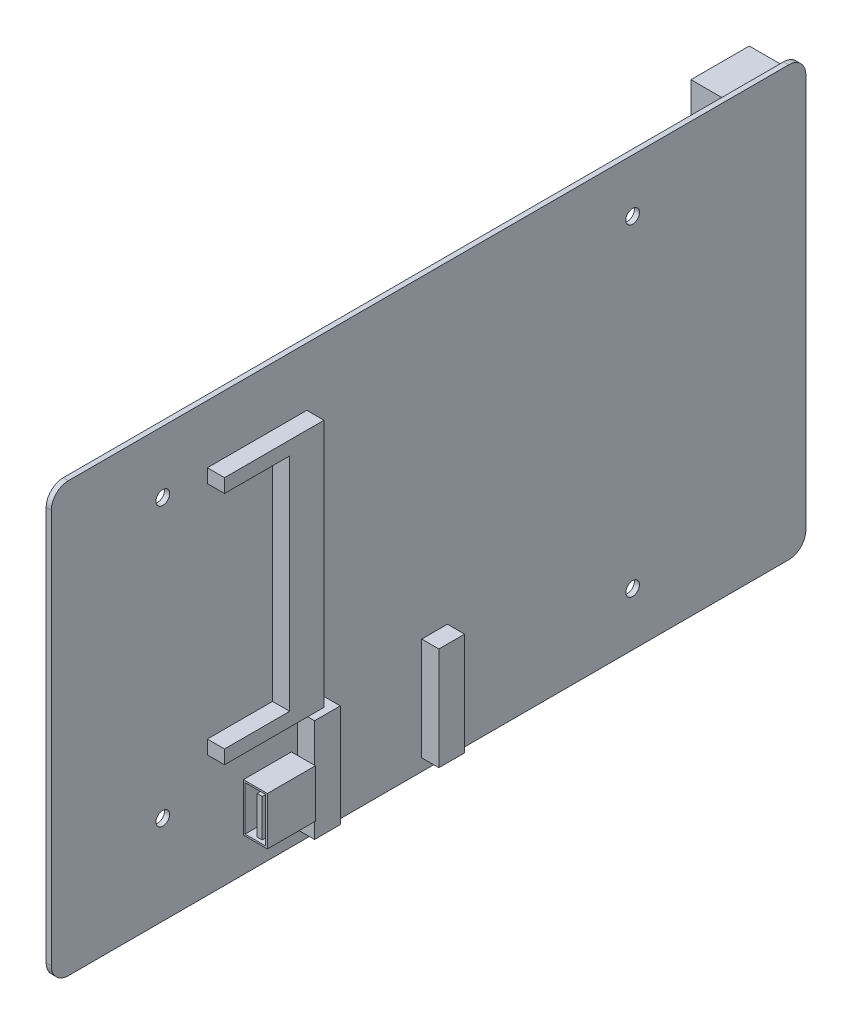
from build123d import *

# Parameters (mm, degrees)
SKETCH_1_W             = 220
SKETCH_1_H             = 125
EXTRUDE_1_DEPTH        = 1.5
FILLET_1_R             = 5
SKETCH_2_W             = 7.5
SKETCH_2_H             = 30
EXTRUDE_2_DEPTH        = 5
SKETCH_3_W             = 14
SKETCH_3_H             = 14
EXTRUDE_3_DEPTH        = 7
SKETCH_4_W             = 6
SKETCH_4_H             = 13
SKETCH_4_W_2           = 1.5
SKETCH_4_H_2           = 11
CUT_EXTRUDE_1_DEPTH    = 10
SKETCH_5_R             = 2
CUT_EXTRUDE_2_DEPTH    = 2.5
SKETCH_6_W             = 82.5
SKETCH_6_H             = 63.5
EXTRUDE_4_DEPTH        = 18
FILLET_2_R             = 1
SKETCH_7_W             = 82.5
SKETCH_7_H             = 2.5
CUT_EXTRUDE_3_DEPTH    = 10
PATTERN_LINEAR_1_COUNT = 18
PATTERN_LINEAR_1_PITCH = 3.4
SKETCH_8_W             = 1.5
SKETCH_8_H             = 63.5
CUT_EXTRUDE_4_DEPTH    = 10
PATTERN_LINEAR_2_COUNT = 5
PATTERN_LINEAR_2_PITCH = 11
SKETCH_9_W             = 8.75
SKETCH_9_H             = 39
EXTRUDE_5_DEPTH        = 11
SKETCH_10_W            = 2
SKETCH_10_H            = 11.5
SKETCH_10_H_2          = 22
CUT_EXTRUDE_5_DEPTH    = 7.5
SKETCH_11_W            = 17
SKETCH_11_H            = 14
EXTRUDE_6_DEPTH        = 15
SKETCH_12_W            = 5.5
SKETCH_12_H            = 13
SKETCH_12_W_2          = 1.5
SKETCH_12_H_2          = 11
CUT_EXTRUDE_6_DEPTH    = 10
SKETCH_13_W            = 16
SKETCH_13_H            = 16.5
EXTRUDE_7_DEPTH        = 13.5
CUT_EXTRUDE_7_DEPTH    = 13.5
PATTERN_LINEAR_3_COUNT = 2
PATTERN_LINEAR_3_PITCH = 20.5


with BuildPart() as part:
    # 草图1 → 凸台-拉伸1 (new body)
    with BuildSketch(Plane(origin=(0, 0, 0), x_dir=(0, 0, -1), z_dir=(1, 0, 0))):
        Rectangle(SKETCH_1_W, SKETCH_1_H)
    extrude(amount=-EXTRUDE_1_DEPTH)

    # 圆角1
    fillet_1_edges = [part.edges().sort_by_distance(p)[0] for p in [
        (-0.75, 62.5, 110),
        (-0.75, 62.5, -110),
        (-0.75, -62.5, -110),
        (-0.75, -62.5, 110),
    ]]
    fillet(fillet_1_edges, radius=FILLET_1_R)

    # 草图2 → 凸台-拉伸2 (add)
    with BuildSketch(Plane(origin=(0, 0, 0), x_dir=(0, 0, -1), z_dir=(1, 0, 0))):
        Polygon((-35.5, 45.5), (-64.5, 45.5), (-64.5, 41.5), (-45.5, 41.5), (-45.5, -23), (-64.5, -23), (-64.5, -27), (-35.5, -27), align=None)
        with Locations((-34.5, -44)):
            Rectangle(SKETCH_2_W, SKETCH_2_H)
        with Locations((1.75, -44)):
            Rectangle(SKETCH_2_W, SKETCH_2_H)
    extrude(amount=EXTRUDE_2_DEPTH)

    # 草图3 → 凸台-拉伸3 (add)
    with BuildSketch(Plane(origin=(0, 0, 0), x_dir=(0, 0, -1), z_dir=(1, 0, 0))):
        with Locations((-47, -45.5)):
            Rectangle(SKETCH_3_W, SKETCH_3_H)
    extrude(amount=EXTRUDE_3_DEPTH)

    # 草图4 → 切除-拉伸1 (cut)
    with BuildSketch(Plane.XY.offset(54)):
        with Locations((3.5, -45.5)):
            Rectangle(SKETCH_4_W, SKETCH_4_H)
        with Locations((4.75, -45.5)):
            Rectangle(SKETCH_4_W_2, SKETCH_4_H_2, mode=Mode.SUBTRACT)
    extrude(amount=-CUT_EXTRUDE_1_DEPTH, mode=Mode.SUBTRACT)

    # 草图5 → 切除-拉伸2 (cut, through all)
    with BuildSketch(Plane(origin=(0, 0, 0), x_dir=(0, 0, -1), z_dir=(1, 0, 0))):
        with Locations((-77.5, 44.5)):
            Circle(SKETCH_5_R)
        with Locations((-77.5, -36.5)):
            Circle(SKETCH_5_R)
        with Locations((59.5, 47)):
            Circle(SKETCH_5_R)
        with Locations((59.5, -47)):
            Circle(SKETCH_5_R)
    extrude(amount=-CUT_EXTRUDE_2_DEPTH, mode=Mode.SUBTRACT)

    # 草图6 → 凸台-拉伸4 (add)
    with BuildSketch(Plane.ZY.offset(1.5)):
        with Locations((-6.25, 10.75)):
            Rectangle(SKETCH_6_W, SKETCH_6_H)
    extrude(amount=EXTRUDE_4_DEPTH)

    # 圆角2
    fillet_2_edges = [part.edges().sort_by_distance(p)[0] for p in [
        (-19.5, 10.75, -47.5),
        (-19.5, 10.75, 35),
    ]]
    fillet(fillet_2_edges, radius=FILLET_2_R)

    # 草图7 → 切除-拉伸3 (cut)
    with BuildSketch(Plane.ZY.offset(19.5)):
        with Locations((-6.25, -18.75)):
            Rectangle(SKETCH_7_W, SKETCH_7_H)
    cut_extrude_3 = extrude(amount=-CUT_EXTRUDE_3_DEPTH, mode=Mode.SUBTRACT)

    # 阵列(线性)1: 切除-拉伸3 ×18
    with Locations(*[(0, i * PATTERN_LINEAR_1_PITCH, 0) for i in range(1, PATTERN_LINEAR_1_COUNT)]):
        add(cut_extrude_3, mode=Mode.SUBTRACT)

    # 草图8 → 切除-拉伸4 (cut)
    with BuildSketch(Plane.ZY.offset(19.5)):
        with Locations((-30.75, 10.75)):
            Rectangle(SKETCH_8_W, SKETCH_8_H)
    cut_extrude_4 = extrude(amount=-CUT_EXTRUDE_4_DEPTH, mode=Mode.SUBTRACT)

    # 阵列(线性)2: 切除-拉伸4 ×5
    with Locations(*[(0, 0, i * PATTERN_LINEAR_2_PITCH) for i in range(1, PATTERN_LINEAR_2_COUNT)]):
        add(cut_extrude_4, mode=Mode.SUBTRACT)

    # 草图9 → 凸台-拉伸5 (add)
    with BuildSketch(Plane.ZY.offset(1.5)):
        with Locations((-71.125, -21)):
            Rectangle(SKETCH_9_W, SKETCH_9_H)
    extrude(amount=EXTRUDE_5_DEPTH)

    # 草图10 → 切除-拉伸5 (cut)
    with BuildSketch(Plane.ZY.offset(12.5)):
        with Locations((-71.5, -32.75)):
            Rectangle(SKETCH_10_W, SKETCH_10_H)
        with Locations((-71.5, -14.5)):
            Rectangle(SKETCH_10_W, SKETCH_10_H_2)
    extrude(amount=-CUT_EXTRUDE_5_DEPTH, mode=Mode.SUBTRACT)

    # 草图11 → 凸台-拉伸6 (add)
    with BuildSketch(Plane.ZY.offset(1.5)):
        with Locations((-101.5, 49.5)):
            Rectangle(SKETCH_11_W, SKETCH_11_H)
    extrude(amount=EXTRUDE_6_DEPTH)

    # 草图12 → 切除-拉伸6 (cut)
    with BuildSketch(Plane(origin=(0, 0, -110), x_dir=(-1, 0, 0), z_dir=(0, 0, -1))):
        with Locations((13.25, 49.5)):
            Rectangle(SKETCH_12_W, SKETCH_12_H)
        with Locations((14.25, 49.5)):
            Rectangle(SKETCH_12_W_2, SKETCH_12_H_2, mode=Mode.SUBTRACT)
        with Locations((4.75, 49.5)):
            Rectangle(SKETCH_12_W, SKETCH_12_H)
        with Locations((5.75, 49.5)):
            Rectangle(SKETCH_12_W_2, SKETCH_12_H_2, mode=Mode.SUBTRACT)
    extrude(amount=-CUT_EXTRUDE_6_DEPTH, mode=Mode.SUBTRACT)

    # 草图13 → 凸台-拉伸7 (add)
    with BuildSketch(Plane.ZY.offset(1.5)):
        with Locations((-102, 23.75)):
            Rectangle(SKETCH_13_W, SKETCH_13_H)
    extrude_7 = extrude(amount=EXTRUDE_7_DEPTH)

    # 草图14 → 切除-拉伸7 (cut)
    with BuildSketch(Plane(origin=(0, 0, -110), x_dir=(-1, 0, 0), z_dir=(0, 0, -1))):
        Polygon((11, 20.75), (11, 17.5), (3.5, 17.5), (3.5, 30), (11, 30), (11, 26.75), (14, 26.75), (14, 20.75), align=None)
    cut_extrude_7 = extrude(amount=-CUT_EXTRUDE_7_DEPTH, mode=Mode.SUBTRACT)

    # 阵列(线性)3: 凸台-拉伸7, 切除-拉伸7 ×2
    with Locations(*[(0, -i * PATTERN_LINEAR_3_PITCH, 0) for i in range(1, PATTERN_LINEAR_3_COUNT)]):
        add(extrude_7)
        add(cut_extrude_7, mode=Mode.SUBTRACT)


solid = part.part
